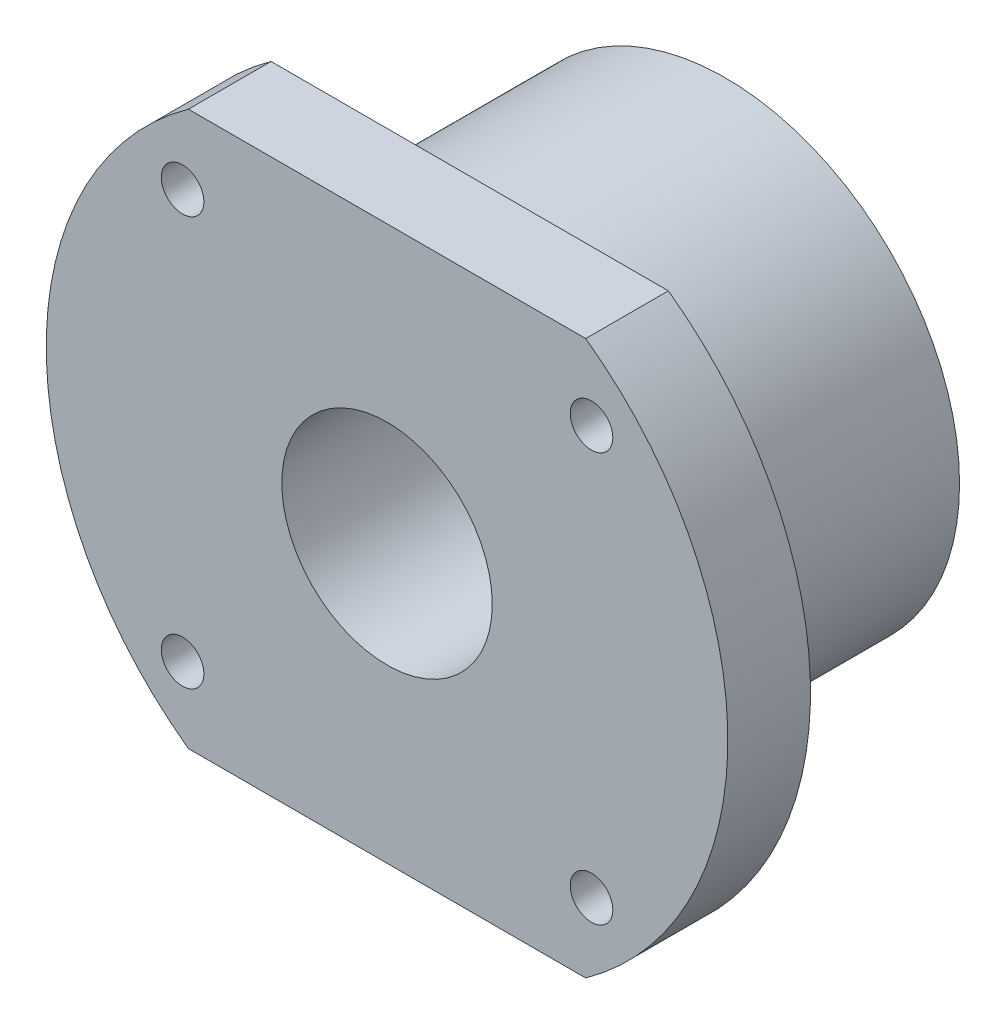
from build123d import *

# Parameters (mm, degrees)
SZKIC1_R                    = 27.5
DODANIE_WYCI_GNI_CIE1_DEPTH = 30
SZKIC2_R                    = 40
DODANIE_WYCI_GNI_CIE2_DEPTH = 9.7
SZKIC3_W                    = 108.783825326
SZKIC3_H                    = 7.5
WYTNIJ_WYCI_GNI_CIE1_DEPTH  = 9.7
SZKIC5_W                    = 108.783825325
SZKIC5_H                    = 7.5
WYTNIJ_WYCI_GNI_CIE2_DEPTH  = 9.7
SZKIC6_R                    = 12.35
WYTNIJ_WYCI_GNI_CIE3_DEPTH  = 39.7
SZKIC7_R                    = 2.5
WYTNIJ_WYCI_GNI_CIE4_DEPTH  = 9.7


with BuildPart() as part:
    # Szkic1 → Dodanie-wyciągnięcie1 (new body)
    with BuildSketch(Plane.XY):
        Circle(SZKIC1_R)
    extrude(amount=DODANIE_WYCI_GNI_CIE1_DEPTH)

    # Szkic2 → Dodanie-wyciągnięcie2 (add)
    with BuildSketch(Plane.XY.offset(30)):
        Circle(SZKIC2_R)
    extrude(amount=DODANIE_WYCI_GNI_CIE2_DEPTH)

    # Szkic3 → Wytnij-wyciągnięcie1 (cut)
    with BuildSketch(Plane.XY.offset(39.7)):
        with Locations((-0.621798063, 36.25)):
            Rectangle(SZKIC3_W, SZKIC3_H)
    extrude(amount=-WYTNIJ_WYCI_GNI_CIE1_DEPTH, mode=Mode.SUBTRACT)

    # Szkic5 → Wytnij-wyciągnięcie2 (cut)
    with BuildSketch(Plane.XY.offset(39.7)):
        with Locations((-3.409138593, -36.25)):
            Rectangle(SZKIC5_W, SZKIC5_H)
    extrude(amount=-WYTNIJ_WYCI_GNI_CIE2_DEPTH, mode=Mode.SUBTRACT)

    # Szkic6 → Wytnij-wyciągnięcie3 (cut)
    with BuildSketch(Plane.XY):
        Circle(SZKIC6_R)
    extrude(amount=WYTNIJ_WYCI_GNI_CIE3_DEPTH, mode=Mode.SUBTRACT)

    # Szkic7 → Wytnij-wyciągnięcie4 (cut)
    with BuildSketch(Plane.XY.offset(39.7)):
        with Locations((-24, 24)):
            Circle(SZKIC7_R)
        with Locations((24, 24)):
            Circle(SZKIC7_R)
        with Locations((-24, -24)):
            Circle(SZKIC7_R)
        with Locations((24, -24)):
            Circle(SZKIC7_R)
    extrude(amount=-WYTNIJ_WYCI_GNI_CIE4_DEPTH, mode=Mode.SUBTRACT)


solid = part.part
